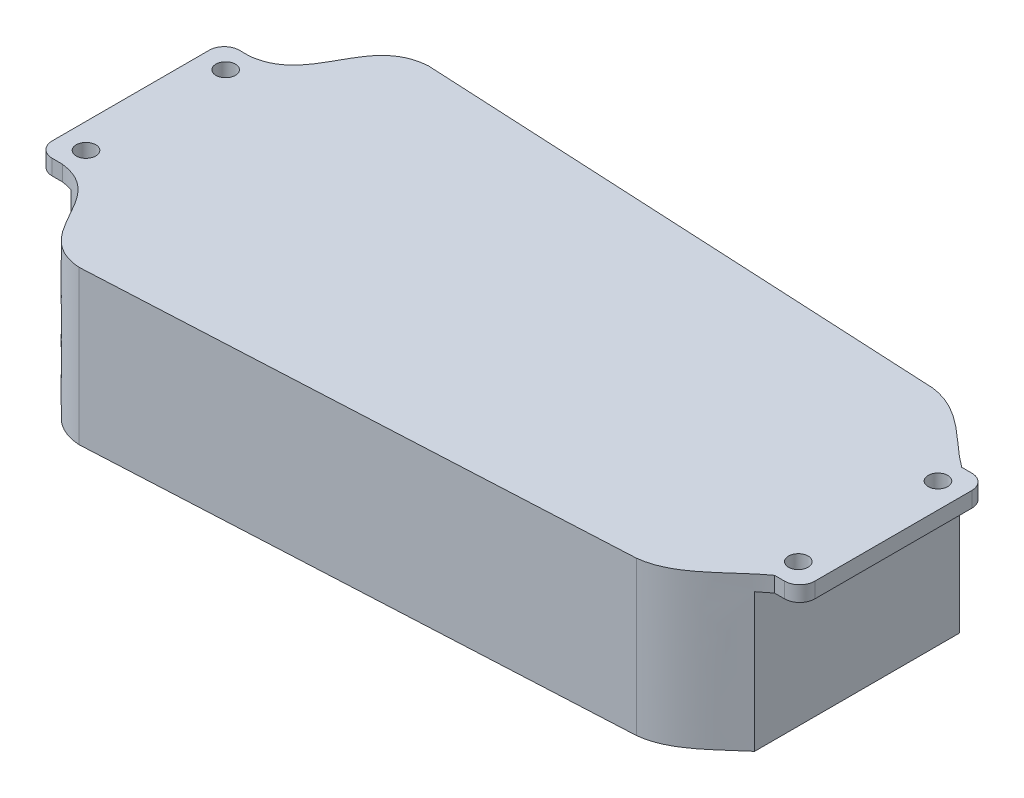
from build123d import *

# Parameters (mm, degrees)
SKETCH1_R           = 3.5
BOSS_EXTRUDE2_DEPTH = 55
SKETCH7_W           = 68.999652055
SKETCH7_H           = 50.415620377
CUT_EXTRUDE5_DEPTH  = 13
SKETCH19_W          = 74.859412742
SKETCH19_H          = 60.725118028
CUT_EXTRUDE7_DEPTH  = 13


with BuildPart() as part:
    # Sketch1 → Boss-Extrude2 (new body)
    with BuildSketch(Plane(origin=(0, 0, 0), x_dir=(1, 0, 0), z_dir=(0, 1, 0))):
        with BuildLine():
            Line((-77.297393365, -66.943127962), (112.637979465, -57.343127962))
            add(Edge.make_bspline(
                [(112.637979465, -57.343127962), (125.082628436, -56.027724614), (133.287763268, -44.662014668), (142.702606635, -37.943127962)],
                knots=[0, 0, 0, 0, 1, 1, 1, 1], degree=3))
            Line((142.702606635, -37.943127962), (146.202606635, -37.943127962))
            Line((146.202606635, -37.943127962), (146.302606635, -37.943127962))
            ThreePointArc((146.302606635, -37.943127962), (150.120983253, -36.36150458), (151.702606635, -32.543127962))
            Line((151.702606635, -32.543127962), (151.702606635, 23.656872038))
            ThreePointArc((151.702606635, 23.656872038), (150.120983253, 27.475248656), (146.302606635, 29.056872038))
            Line((146.302606635, 29.056872038), (146.202606635, 29.056872038))
            Line((146.202606635, 29.056872038), (142.702606635, 29.056872038))
            add(Edge.make_bspline(
                [(112.637979465, 48.456872038), (125.082628436, 47.14146869), (133.287763268, 35.775758744), (142.702606635, 29.056872038)],
                knots=[0, 0, 0, 0, 1, 1, 1, 1], degree=3))
            Line((112.637979465, 48.456872038), (-77.297393365, 58.056872038))
            add(Edge.make_bspline(
                [(-77.297393365, 58.056872038), (-97.47829568, 56.558543187), (-92.669908534, 31.299380259), (-112.297393365, 29.056872038)],
                knots=[0, 0, 0, 0, 1, 1, 1, 1], degree=3))
            Line((-112.297393365, 29.056872038), (-115.797393365, 29.056872038))
            Line((-115.797393365, 29.056872038), (-115.897393365, 29.056872038))
            ThreePointArc((-115.897393365, 29.056872038), (-119.715769983, 27.475248656), (-121.297393365, 23.656872038))
            Line((-121.297393365, 23.656872038), (-121.297393365, -32.543127962))
            ThreePointArc((-121.297393365, -32.543127962), (-119.715769983, -36.36150458), (-115.897393365, -37.943127962))
            Line((-115.897393365, -37.943127962), (-115.797393365, -37.943127962))
            Line((-115.797393365, -37.943127962), (-112.297393365, -37.943127962))
            add(Edge.make_bspline(
                [(-77.297393365, -66.943127962), (-97.47829568, -65.444799111), (-92.669908534, -40.185636183), (-112.297393365, -37.943127962)],
                knots=[0, 0, 0, 0, 1, 1, 1, 1], degree=3))
        make_face()
        with Locations((-112.297393365, 20.556872038)):
            Circle(SKETCH1_R, mode=Mode.SUBTRACT)
        with Locations((-112.297393365, -29.443127962)):
            Circle(SKETCH1_R, mode=Mode.SUBTRACT)
        with Locations((142.702606635, -29.443127962)):
            Circle(SKETCH1_R, mode=Mode.SUBTRACT)
        with Locations((142.702606635, 20.556872038)):
            Circle(SKETCH1_R, mode=Mode.SUBTRACT)
    extrude(amount=-BOSS_EXTRUDE2_DEPTH)

    # Sketch7 → Cut-Extrude5 (cut)
    with BuildSketch(Plane.ZY.offset(121.297393365)):
        with Locations((4.333112833, -30.707810189)):
            Rectangle(SKETCH7_W, SKETCH7_H)
    extrude(amount=-CUT_EXTRUDE5_DEPTH, mode=Mode.SUBTRACT)

    # Sketch19 → Cut-Extrude7 (cut)
    with BuildSketch(Plane(origin=(151.702606635, 0, 0), x_dir=(0, 0, -1), z_dir=(1, 0, 0))):
        with Locations((-5.097493458, -35.862559014)):
            Rectangle(SKETCH19_W, SKETCH19_H)
    extrude(amount=-CUT_EXTRUDE7_DEPTH, mode=Mode.SUBTRACT)


solid = part.part
